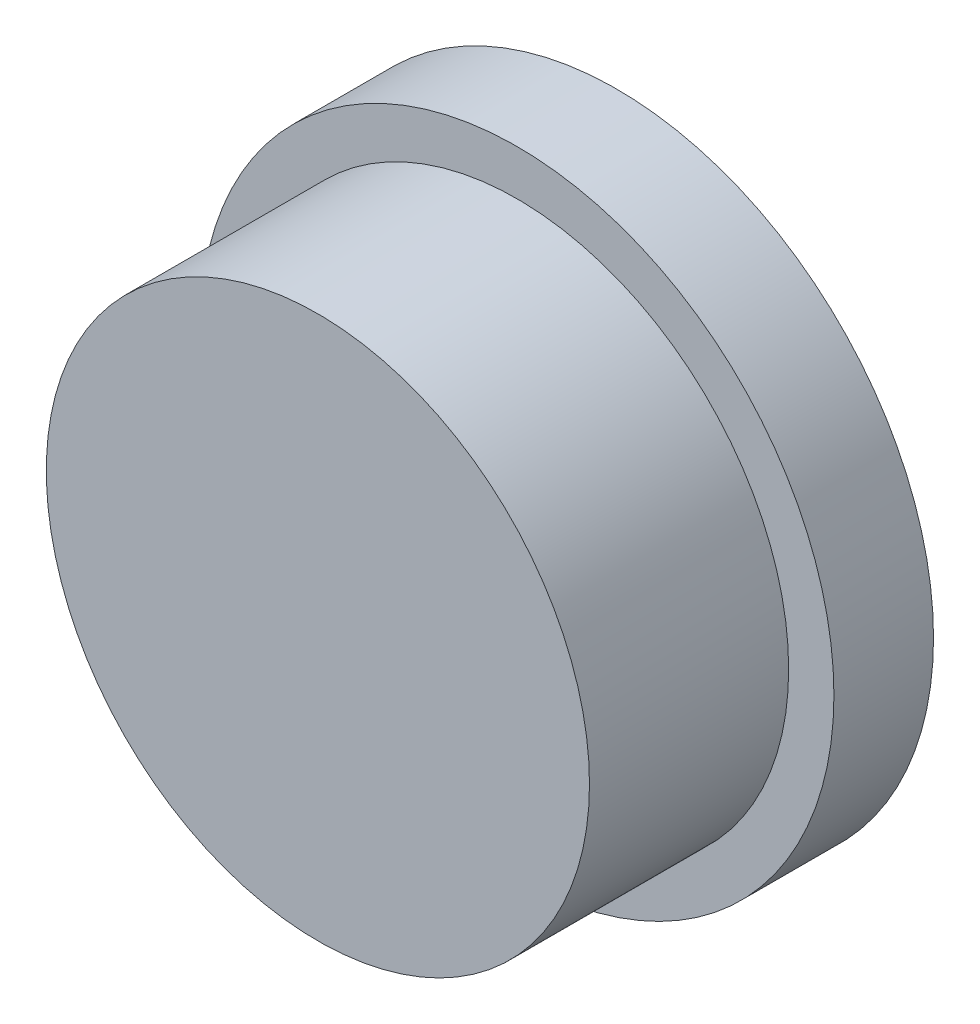
from build123d import *

# Parameters (mm, degrees)
CROQUIS2_R              = 35
CROQUIS2_R_2            = 30
SALIENTE_EXTRUIR1_DEPTH = 11
CROQUIS5_R              = 30
SALIENTE_EXTRUIR3_DEPTH = 22


with BuildPart() as part:
    # Croquis2 → Saliente-Extruir1 (new body)
    with BuildSketch(Plane.XY):
        Circle(CROQUIS2_R)
        Circle(CROQUIS2_R_2, mode=Mode.SUBTRACT)
    extrude(amount=SALIENTE_EXTRUIR1_DEPTH)


with BuildPart() as body_2:
    # Croquis5 → Saliente-Extruir3 (new body)
    with BuildSketch(Plane.XY.offset(11)):
        Circle(CROQUIS5_R)
    extrude(amount=SALIENTE_EXTRUIR3_DEPTH)


solid = Compound([part.part, body_2.part])
